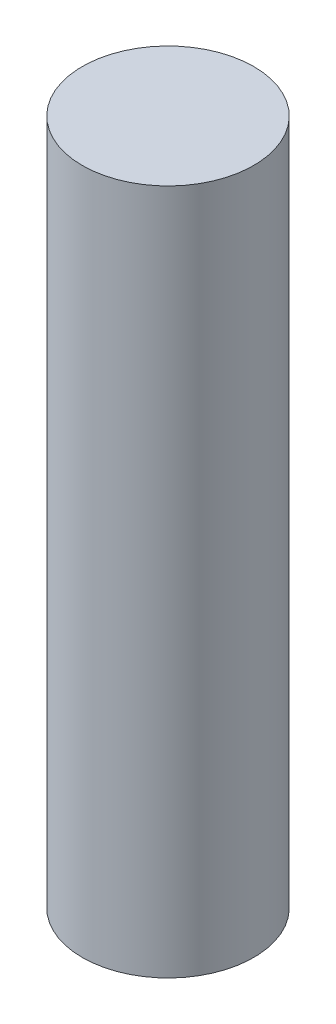
from build123d import *

# Parameters (mm, degrees)
ESQUISSE1_R      = 2
EXTRUSION1_DEPTH = 16


with BuildPart() as part:
    # Esquisse1 → Extrusion1 (new body)
    with BuildSketch(Plane(origin=(0, 0, 0), x_dir=(1, 0, 0), z_dir=(0, 1, 0))):
        Circle(ESQUISSE1_R)
    extrude(amount=EXTRUSION1_DEPTH)


solid = part.part
